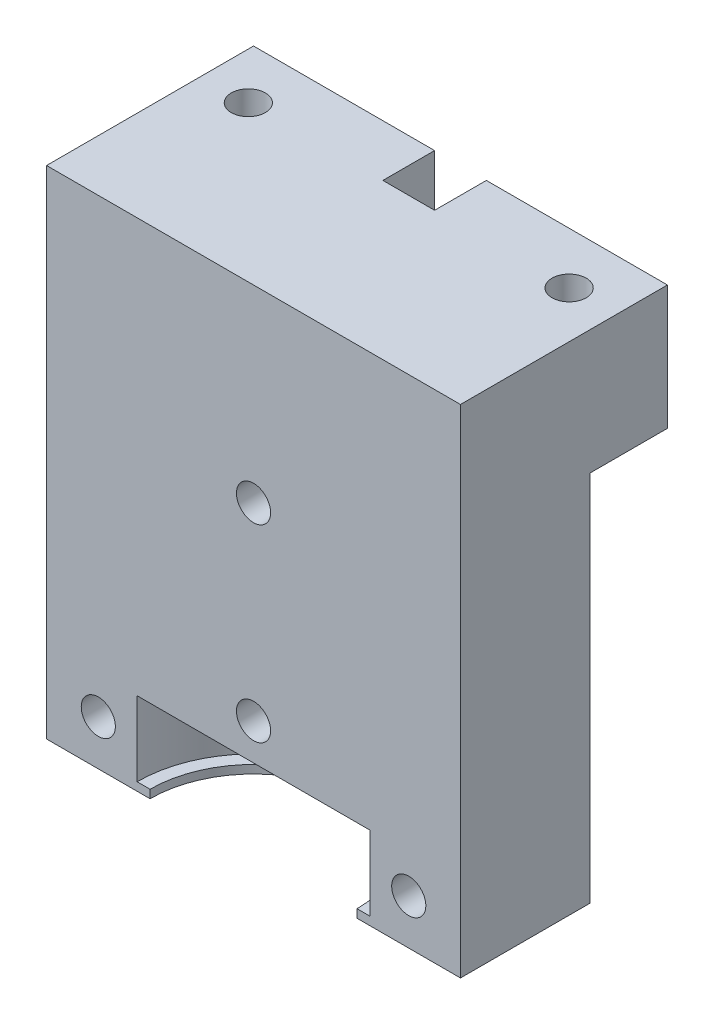
from build123d import *

# Parameters (mm, degrees)
SKETCH1_W             = 40
SKETCH1_H             = 40
BOSS_EXTRUDE1_DEPTH   = 48
M4X0_7_TAPPED_HOLE1_D = 3.3
SKETCH10_W            = 40
SKETCH10_H            = 20
CUT_EXTRUDE4_DEPTH    = 49
SKETCH11_W            = 11.25
SKETCH11_H            = 7.2
CUT_EXTRUDE5_REACH    = 50
SKETCH12_R            = 10
M4X0_7_TAPPED_HOLE2_D = 3.3
SKETCH15_W            = 40
SKETCH15_H            = 7.5
CUT_EXTRUDE6_DEPTH    = 36
SKETCH16_W            = 5
SKETCH16_H            = 5
CUT_EXTRUDE7_DEPTH    = 13


with BuildPart() as part:
    # Sketch1 → Boss-Extrude1 (new body)
    with BuildSketch(Plane(origin=(0, 0, 0), x_dir=(1, 0, 0), z_dir=(0, 1, 0))):
        Rectangle(SKETCH1_W, SKETCH1_H)
    extrude(amount=-BOSS_EXTRUDE1_DEPTH)

    # M4x0.7 Tapped Hole1 (through all)
    with Locations(Plane(origin=(0, 0, 0), x_dir=(1, 0, 0), z_dir=(0, 1, 0))):
        with Locations((-15.5, 15), (15.5, 15), (15.5, -15), (-15.5, -15)):
            Hole(M4X0_7_TAPPED_HOLE1_D / 2)

    # Sketch10 → Cut-Extrude4 (cut, through all)
    with BuildSketch(Plane(origin=(0, 0, 0), x_dir=(1, 0, 0), z_dir=(0, 1, 0))):
        with Locations((0, -10)):
            Rectangle(SKETCH10_W, SKETCH10_H)
    extrude(amount=-CUT_EXTRUDE4_DEPTH, mode=Mode.SUBTRACT)

    # Sketch11 → Cut-Revolve2 (revolve, cut)
    with BuildSketch(Plane.XY):
        with Locations((5.625, -43.6)):
            Rectangle(SKETCH11_W, SKETCH11_H)
    revolve(axis=Axis((0, 0, 0), (0, -1, 0)), mode=Mode.SUBTRACT)

    # Sketch12 → Cut-Extrude5 (cut, up to next)
    with BuildSketch(Plane.XZ.offset(48), mode=Mode.PRIVATE) as cut_extrude5_sk1:
        Circle(SKETCH12_R)
    cut_extrude5_tool1 = extrude(cut_extrude5_sk1.sketch, amount=-CUT_EXTRUDE5_REACH, mode=Mode.PRIVATE) & part.part
    add(cut_extrude5_tool1.solids().sort_by_distance((0, -48, 0))[0], mode=Mode.SUBTRACT)

    # M4x0.7 Tapped Hole2 (through all)
    with Locations(Plane(origin=(0, 0, -20), x_dir=(-1, 0, 0), z_dir=(0, 0, -1))):
        with Locations((15, -43.628125), (-15, -43.628125), (0, -36.484375), (0, -18.2421875)):
            Hole(M4X0_7_TAPPED_HOLE2_D / 2)

    # Sketch15 → Cut-Extrude6 (cut)
    with BuildSketch(Plane.XZ.offset(48)):
        with Locations((0, -16.25)):
            Rectangle(SKETCH15_W, SKETCH15_H)
    extrude(amount=-CUT_EXTRUDE6_DEPTH, mode=Mode.SUBTRACT)

    # Sketch16 → Cut-Extrude7 (cut, through all)
    with BuildSketch(Plane.XZ.offset(12)):
        with Locations((0, -17.5)):
            Rectangle(SKETCH16_W, SKETCH16_H)
    extrude(amount=-CUT_EXTRUDE7_DEPTH, mode=Mode.SUBTRACT)


solid = part.part
